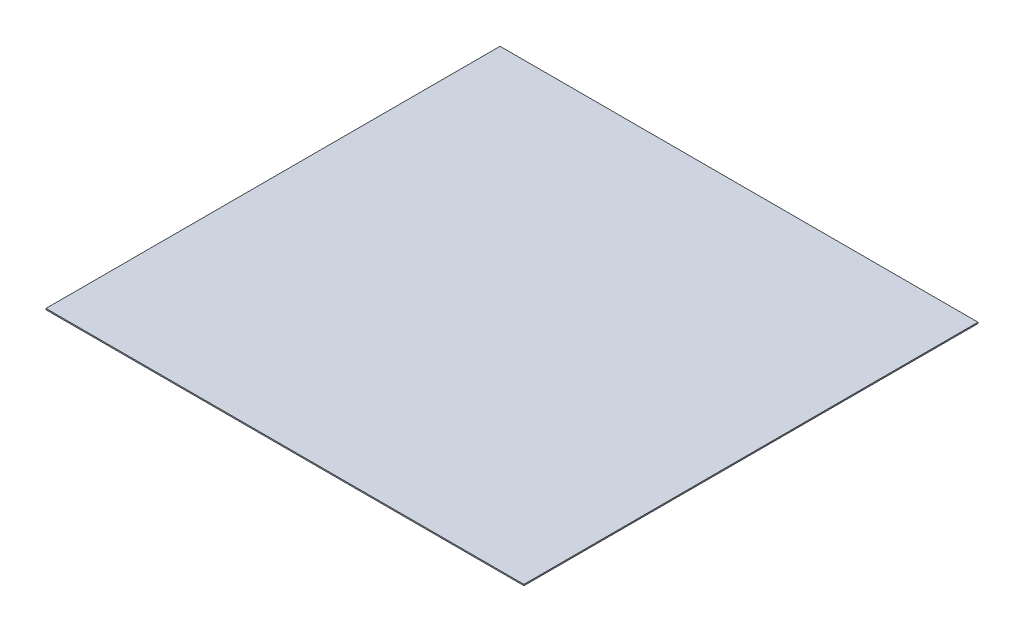
from build123d import *

# Parameters (mm, degrees)
SZKIC1_W                    = 800
SZKIC1_H                    = 760
DODANIE_WYCI_GNI_CIE1_DEPTH = 2


with BuildPart() as part:
    # Szkic1 → Dodanie-wyciągnięcie1 (new body)
    with BuildSketch(Plane(origin=(0, 0, 0), x_dir=(1, 0, 0), z_dir=(0, 1, 0))):
        with Locations((-197.537105727, 16.208530806)):
            Rectangle(SZKIC1_W, SZKIC1_H)
    extrude(amount=DODANIE_WYCI_GNI_CIE1_DEPTH)


solid = part.part
